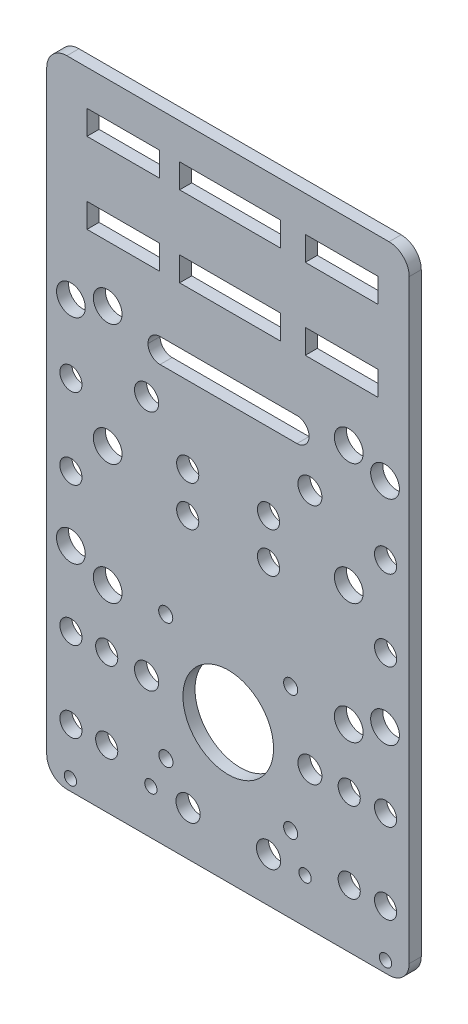
from build123d import *

# Parameters (mm, degrees)
MODEL_R             = 2.75
MODEL_R_2           = 1.524
MODEL_R_3           = 3.57
MODEL_R_4           = 3
MODEL_R_5           = 1.75
MODEL_R_6           = 2.988685284
MODEL_R_7           = 11.25
MODEL_W             = 18.00197115
MODEL_H             = 6.02504647
MODEL_W_2           = 25.001971156
MODEL_H_2           = 6.025046469
BOSS_EXTRUDE2_DEPTH = 3


with BuildPart() as part:
    # Model → Boss-Extrude2 (new body)
    with BuildSketch(Plane.XY):
        with BuildLine():
            Line((-1558.170802496, 1596.031612088), (-1558.170802496, 1743.759047656))
            ThreePointArc((-1558.170802496, 1743.759047656), (-1559.633113999, 1747.298520787), (-1563.170804742, 1748.765139071))
            Line((-1563.170804742, 1748.765139071), (-1643.16842822, 1748.765139071))
            ThreePointArc((-1643.16842822, 1748.765139071), (-1646.706118961, 1747.298520788), (-1648.168430466, 1743.759047658))
            Line((-1648.168430466, 1743.759047658), (-1648.168430466, 1596.031606131))
            ThreePointArc((-1648.168430466, 1596.031606131), (-1646.703964372, 1592.496072226), (-1643.168430466, 1591.031606131))
            Line((-1643.168430466, 1591.031606131), (-1563.170808452, 1591.031606131))
            ThreePointArc((-1563.170808452, 1591.031606131), (-1559.63526859, 1592.496072225), (-1558.170802496, 1596.031612088))
        make_face()
        with Locations((-1573.06309524, 1605.466177477)):
            Circle(MODEL_R, mode=Mode.SUBTRACT)
        with Locations((-1573.06309524, 1625.466177477)):
            Circle(MODEL_R, mode=Mode.SUBTRACT)
        with Locations((-1633.276137722, 1605.466177477)):
            Circle(MODEL_R, mode=Mode.SUBTRACT)
        with Locations((-1633.276137722, 1625.466177477)):
            Circle(MODEL_R, mode=Mode.SUBTRACT)
        with Locations((-1564.034669062, 1605.466177486)):
            Circle(MODEL_R, mode=Mode.SUBTRACT)
        with Locations((-1642.166137722, 1605.466177477)):
            Circle(MODEL_R, mode=Mode.SUBTRACT)
        with Locations((-1564.034669062, 1625.466177486)):
            Circle(MODEL_R, mode=Mode.SUBTRACT)
        with Locations((-1642.166137722, 1625.466177477)):
            Circle(MODEL_R, mode=Mode.SUBTRACT)
        with Locations((-1564.0520997, 1593.809639733)):
            Circle(MODEL_R_2, mode=Mode.SUBTRACT)
        with Locations((-1584.028829584, 1602.080803539)):
            Circle(MODEL_R_2, mode=Mode.SUBTRACT)
        with Locations((-1642.287133262, 1593.809639733)):
            Circle(MODEL_R_2, mode=Mode.SUBTRACT)
        with Locations((-1622.310403377, 1602.080803539)):
            Circle(MODEL_R_2, mode=Mode.SUBTRACT)
        with Locations((-1564.034669062, 1679.892967716)):
            Circle(MODEL_R, mode=Mode.SUBTRACT)
        with Locations((-1564.034669062, 1659.936167716)):
            Circle(MODEL_R, mode=Mode.SUBTRACT)
        with Locations((-1642.166137722, 1679.892967726)):
            Circle(MODEL_R, mode=Mode.SUBTRACT)
        with Locations((-1642.166137722, 1659.936167726)):
            Circle(MODEL_R, mode=Mode.SUBTRACT)
        with Locations((-1633.028888044, 1669.901183151)):
            Circle(MODEL_R_3, mode=Mode.SUBTRACT)
        with Locations((-1633.027603994, 1699.99200382)):
            Circle(MODEL_R_3, mode=Mode.SUBTRACT)
        with Locations((-1633.027603994, 1639.99200382)):
            Circle(MODEL_R_3, mode=Mode.SUBTRACT)
        with Locations((-1642.168430466, 1643.881204835)):
            Circle(MODEL_R_3, mode=Mode.SUBTRACT)
        with Locations((-1642.168430466, 1696.860624835)):
            Circle(MODEL_R_3, mode=Mode.SUBTRACT)
        with Locations((-1564.170802496, 1643.881204835)):
            Circle(MODEL_R_3, mode=Mode.SUBTRACT)
        with Locations((-1573.17191871, 1669.901183151)):
            Circle(MODEL_R_3, mode=Mode.SUBTRACT)
        with Locations((-1613.166137692, 1674.864567716)):
            Circle(MODEL_R, mode=Mode.SUBTRACT)
        with Locations((-1593.100403377, 1674.880803539)):
            Circle(MODEL_R, mode=Mode.SUBTRACT)
        with Locations((-1613.077133262, 1602.064639733)):
            Circle(MODEL_R_4, mode=Mode.SUBTRACT)
        with Locations((-1593.100403377, 1602.080803539)):
            Circle(MODEL_R_4, mode=Mode.SUBTRACT)
        with Locations((-1564.170802496, 1696.860624835)):
            Circle(MODEL_R_3, mode=Mode.SUBTRACT)
        with Locations((-1613.166137692, 1664.864567716)):
            Circle(MODEL_R, mode=Mode.SUBTRACT)
        with Locations((-1618.57210033, 1609.927346224)):
            Circle(MODEL_R_5, mode=Mode.SUBTRACT)
        with Locations((-1618.625460969, 1640.924100772)):
            Circle(MODEL_R_5, mode=Mode.SUBTRACT)
        with Locations((-1593.100403377, 1664.880803539)):
            Circle(MODEL_R, mode=Mode.SUBTRACT)
        with Locations((-1573.17320276, 1699.99200382)):
            Circle(MODEL_R_3, mode=Mode.SUBTRACT)
        with Locations((-1623.370056938, 1685.360521432)):
            Circle(MODEL_R_4, mode=Mode.SUBTRACT)
        with Locations((-1582.81965611, 1685.466121434)):
            Circle(MODEL_R_6, mode=Mode.SUBTRACT)
        with Locations((-1623.370056938, 1625.360521432)):
            Circle(MODEL_R_4, mode=Mode.SUBTRACT)
        with Locations((-1582.81965611, 1625.466121434)):
            Circle(MODEL_R_6, mode=Mode.SUBTRACT)
        with Locations((-1587.603603064, 1609.952403818)):
            Circle(MODEL_R_5, mode=Mode.SUBTRACT)
        with Locations((-1587.600403377, 1640.949204131)):
            Circle(MODEL_R_5, mode=Mode.SUBTRACT)
        with Locations((-1603.100403377, 1625.452403818)):
            Circle(MODEL_R_7, mode=Mode.SUBTRACT)
        with Locations((-1573.17320276, 1639.99200382)):
            Circle(MODEL_R_3, mode=Mode.SUBTRACT)
        Polygon((-1583.977814187, 1713.92640548), (-1583.977814187, 1719.951451949), (-1568.975843031, 1719.951451949), (-1565.975843031, 1719.951451949), (-1565.975843031, 1713.92640548), (-1568.975843031, 1713.92640548), align=None, mode=Mode.SUBTRACT)
        with Locations((-1629.171788075, 1716.938928715)):
            Rectangle(MODEL_W, MODEL_H, mode=Mode.SUBTRACT)
        with Locations((-1629.171788075, 1736.938928715)):
            Rectangle(MODEL_W, MODEL_H, mode=Mode.SUBTRACT)
        Polygon((-1583.977814187, 1733.92640548), (-1583.977814187, 1739.951451949), (-1568.975843031, 1739.951451949), (-1565.975843031, 1739.951451949), (-1565.975843031, 1733.92640548), (-1568.975843031, 1733.92640548), align=None, mode=Mode.SUBTRACT)
        with Locations((-1602.671788074, 1716.938928714)):
            Rectangle(MODEL_W_2, MODEL_H_2, mode=Mode.SUBTRACT)
        with Locations((-1602.671788074, 1736.938928714)):
            Rectangle(MODEL_W_2, MODEL_H_2, mode=Mode.SUBTRACT)
        with BuildLine():
            Line((-1583.030566378, 1696.955805603), (-1583.030566378, 1696.93660548))
            ThreePointArc((-1583.030566378, 1696.93660548), (-1583.909246034, 1694.815285137), (-1586.030566378, 1693.93660548))
            Line((-1586.030566378, 1693.93660548), (-1620.030566378, 1693.93660548))
            ThreePointArc((-1620.030566378, 1693.93660548), (-1622.151886721, 1694.815285137), (-1623.030566378, 1696.93660548))
            Line((-1623.030566378, 1696.93660548), (-1623.030566378, 1696.955805603))
            ThreePointArc((-1623.030566378, 1696.955805603), (-1622.151886721, 1699.077125947), (-1620.030566378, 1699.955805603))
            Line((-1620.030566378, 1699.955805603), (-1586.030566378, 1699.955805603))
            ThreePointArc((-1586.030566378, 1699.955805603), (-1583.909246034, 1699.077125947), (-1583.030566378, 1696.955805603))
        make_face(mode=Mode.SUBTRACT)
    extrude(amount=BOSS_EXTRUDE2_DEPTH)


solid = part.part
